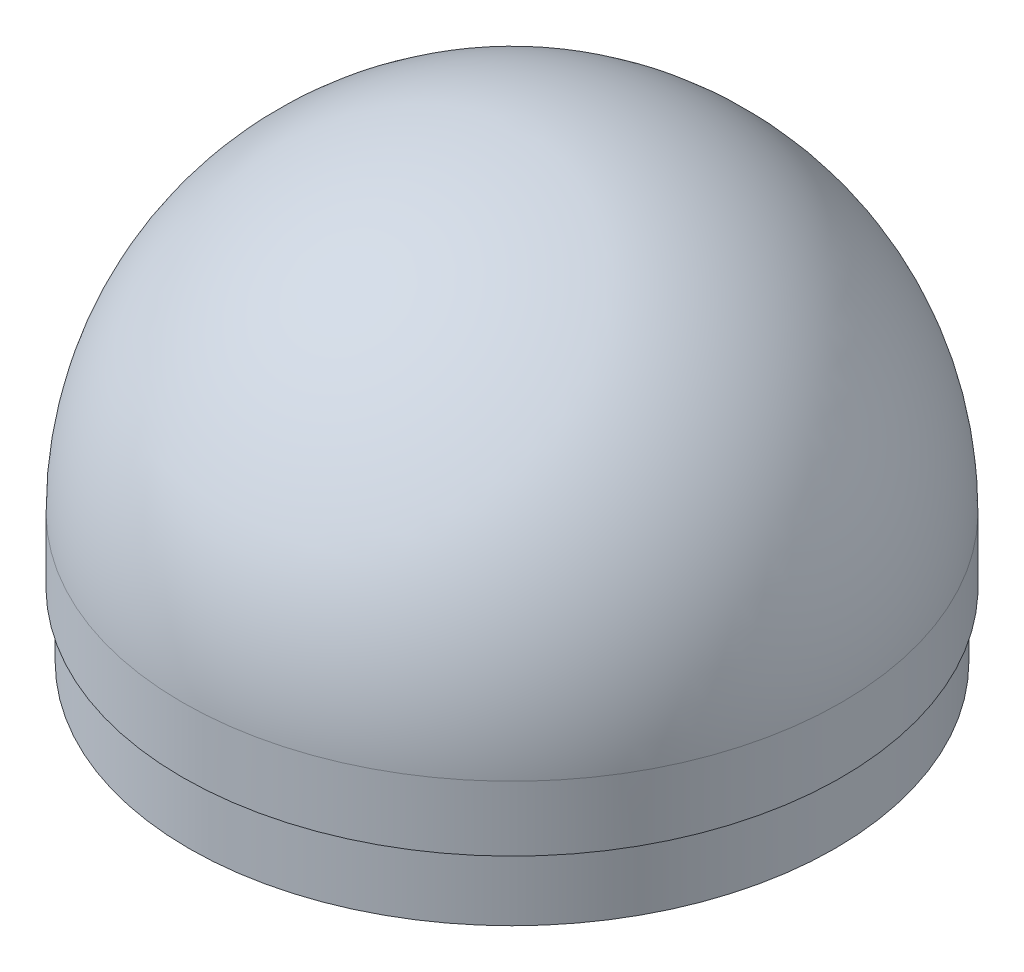
from build123d import *


with BuildPart() as part:
    # Sketch1 → Revolve1 (revolve)
    with BuildSketch(Plane.XY):
        with BuildLine():
            Line((0, 1127), (0, 1122))
            ThreePointArc((0, 1122), (86.267027305, 1086.267027305), (122, 1000))
            Line((122, 1000), (122, 950))
            Line((122, 950), (124.5, 950))
            Line((124.5, 950), (124.5, 975))
            Line((124.5, 975), (127, 975))
            Line((127, 975), (127, 1000))
            ThreePointArc((127, 1000), (89.802561211, 1089.802561211), (0, 1127))
        make_face()
    revolve(axis=Axis((0, 1000, 0), (0, -1, 0)))


solid = part.part
